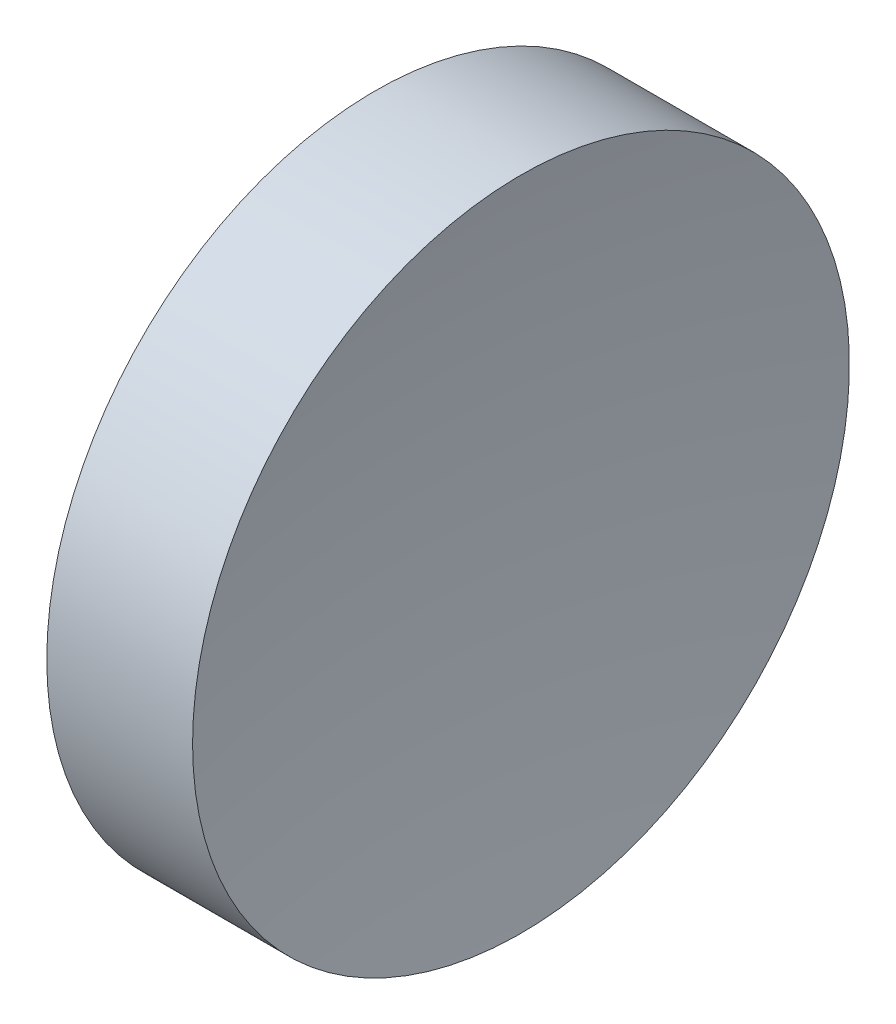
from build123d import *


with BuildPart() as part:
    # 草图1 → 旋转1 (revolve)
    with BuildSketch(Plane.XY, mode=Mode.PRIVATE) as revolve_1_sk:
        with BuildLine():
            Line((230.18531107, 138.756042247), (230.18531107, 163.756042247))
            Line((230.18531107, 163.756042247), (241.283315448, 163.756042247))
            ThreePointArc((241.283315448, 163.756042247), (239.71073103, 151.299981313), (239.185308874, 138.756042247))
            Line((239.185308874, 138.756042247), (230.18531107, 138.756042247))
        make_face()
    revolve(revolve_1_sk.sketch.rotate(Axis((217.970286004, 138.756042247, 0), (1, 0, 0)), 90), axis=Axis((217.970286004, 138.756042247, 0), (1, 0, 0)))  # turned: the seam where the file's is


solid = part.part
